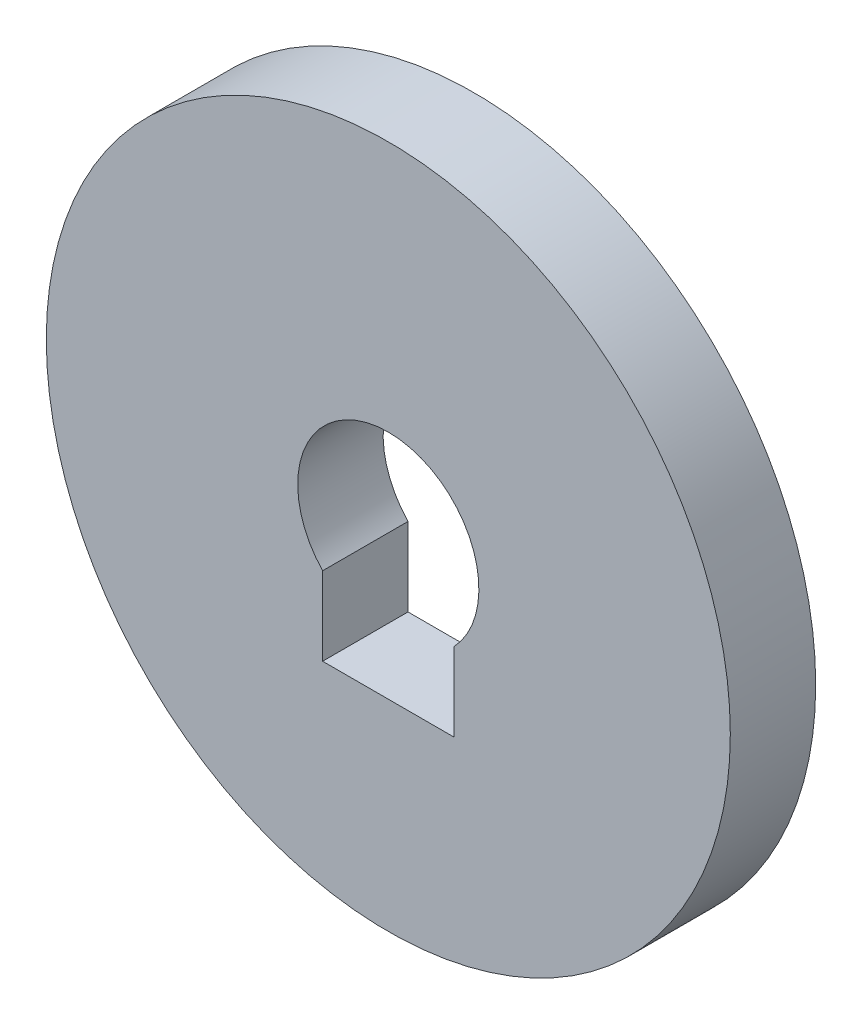
from build123d import *

# Parameters (mm, degrees)
BOSS_EXTRUDE2_DEPTH = 91


with BuildPart() as part:
    # Sketch1 → Boss-Extrude2 (new body)
    with BuildSketch(Plane.XY):
        with BuildLine():
            ThreePointArc((364.5, 0), (-257.740421742, 257.740421742), (0, -364.5))
            ThreePointArc((0, -364.5), (257.740421742, -257.740421742), (364.5, 0))
        make_face()
        with BuildLine():
            Line((70, -150), (0, -150))
            Line((0, -150), (-70, -150))
            Line((-70, -150), (-70, -66.467106312))
            ThreePointArc((-70, -66.467106312), (-35.78292841, 89.651872573), (96.529147005, 0))
            ThreePointArc((96.529147005, 0), (89.651872573, -35.78292841), (70, -66.467106312))
            Line((70, -66.467106312), (70, -150))
        make_face(mode=Mode.SUBTRACT)
    extrude(amount=BOSS_EXTRUDE2_DEPTH)


solid = part.part
